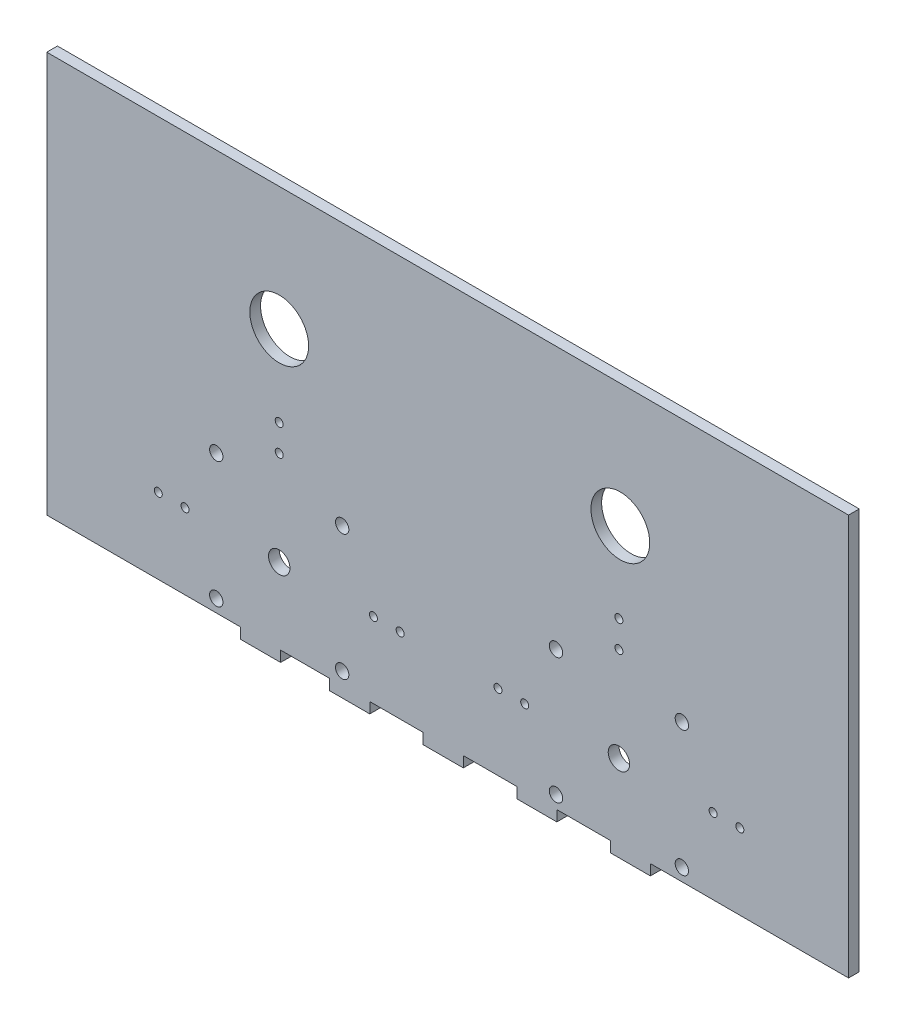
from build123d import *

# Parameters (mm, degrees)
SKETCH1_R           = 1.5
SKETCH1_R_2         = 11
SKETCH1_R_3         = 4
SKETCH1_R_4         = 2.5
BOSS_EXTRUDE2_DEPTH = 4


with BuildPart() as part:
    # Sketch1 → Boss-Extrude2 (new body)
    with BuildSketch(Plane.XY):
        Polygon((-150.528484514, 102.663377685), (149.471515486, 102.663377685), (149.471515486, -47.336622315), (75.331349572, -47.336622315), (75.331349572, -51.336622315), (60.331349572, -51.336622315), (60.331349572, -47.336622315), (40.331349572, -47.336622315), (40.331349572, -51.336622315), (25.331349572, -51.336622315), (25.331349572, -47.336622315), (5.331349572, -47.336622315), (5.331349572, -51.336622315), (-9.668650428, -51.336622315), (-9.668650428, -47.336622315), (-29.668650428, -47.336622315), (-29.668650428, -51.336622315), (-44.668650428, -51.336622315), (-44.668650428, -47.336622315), (-63.028484514, -47.336622315), (-63.028484514, -51.336622315), (-78.028484514, -51.336622315), (-78.028484514, -47.336622315), (-150.528484514, -47.336622315), align=None)
        with Locations((-63.55, 16.163377685)):
            Circle(SKETCH1_R, mode=Mode.SUBTRACT)
        with Locations((-63.55, 26.163377685)):
            Circle(SKETCH1_R, mode=Mode.SUBTRACT)
        with Locations((-98.8, -19.086622315)):
            Circle(SKETCH1_R, mode=Mode.SUBTRACT)
        with Locations((-108.8, -19.086622315)):
            Circle(SKETCH1_R, mode=Mode.SUBTRACT)
        with Locations((63.55, 16.163377685)):
            Circle(SKETCH1_R, mode=Mode.SUBTRACT)
        with Locations((63.55, 26.163377685)):
            Circle(SKETCH1_R, mode=Mode.SUBTRACT)
        with Locations((98.8, -19.033393361)):
            Circle(SKETCH1_R, mode=Mode.SUBTRACT)
        with Locations((108.8, -19.033393361)):
            Circle(SKETCH1_R, mode=Mode.SUBTRACT)
        with Locations((64.078484514, 56.464342986)):
            Circle(SKETCH1_R_2, mode=Mode.SUBTRACT)
        with Locations((-63.55, 56.464342986)):
            Circle(SKETCH1_R_2, mode=Mode.SUBTRACT)
        with Locations((-28.3, -19.086622315)):
            Circle(SKETCH1_R, mode=Mode.SUBTRACT)
        with Locations((-18.3, -19.086622315)):
            Circle(SKETCH1_R, mode=Mode.SUBTRACT)
        with Locations((28.3, -19.086622315)):
            Circle(SKETCH1_R, mode=Mode.SUBTRACT)
        with Locations((18.3, -19.086622315)):
            Circle(SKETCH1_R, mode=Mode.SUBTRACT)
        with Locations((63.55, -19.086622315)):
            Circle(SKETCH1_R_3, mode=Mode.SUBTRACT)
        with Locations((40, 4.463377685)):
            Circle(SKETCH1_R_4, mode=Mode.SUBTRACT)
        with Locations((40, -42.636622315)):
            Circle(SKETCH1_R_4, mode=Mode.SUBTRACT)
        with Locations((87.1, 4.463377685)):
            Circle(SKETCH1_R_4, mode=Mode.SUBTRACT)
        with Locations((87.1, -42.636622315)):
            Circle(SKETCH1_R_4, mode=Mode.SUBTRACT)
        with Locations((-40, -42.636622315)):
            Circle(SKETCH1_R_4, mode=Mode.SUBTRACT)
        with Locations((-87.1, 4.463377685)):
            Circle(SKETCH1_R_4, mode=Mode.SUBTRACT)
        with Locations((-87.1, -42.636622315)):
            Circle(SKETCH1_R_4, mode=Mode.SUBTRACT)
        with Locations((-63.55, -19.086622315)):
            Circle(SKETCH1_R_3, mode=Mode.SUBTRACT)
        with Locations((-40, 4.463377685)):
            Circle(SKETCH1_R_4, mode=Mode.SUBTRACT)
    extrude(amount=BOSS_EXTRUDE2_DEPTH)


solid = part.part
